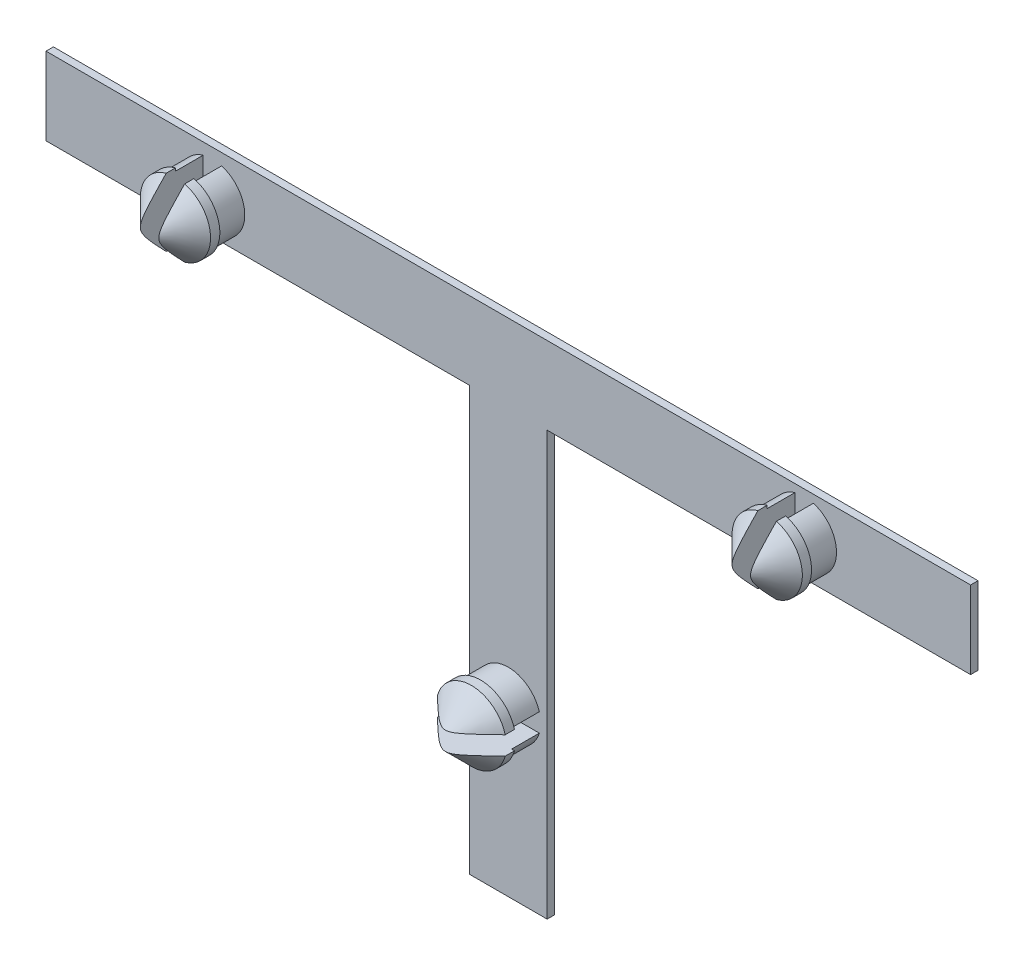
from build123d import *

# Parameters (mm, degrees)
SKICA2_W                 = 50
SKICA2_H                 = 4.2
P_IDAT_VYSUNUT_M2_DEPTH  = 0.4
SKICA3_R                 = 1.75
P_IDAT_VYSUNUT_M3_DEPTH  = 1.5
SKICA5_R                 = 1.9
P_IDAT_VYSUNUT_M5_DEPTH  = 2
ZKOSEN_2_SIZE            = 1.5
SKICA7_W                 = 1
SKICA7_H                 = 5
ODEBRAT_VYSUNUT_M1_DEPTH = 3.5
SKICA8_W                 = 4.2
SKICA8_H                 = 22.9
P_IDAT_VYSUNUT_M6_DEPTH  = 0.4
SKICA9_R                 = 1.75
P_IDAT_VYSUNUT_M7_DEPTH  = 1.5
SKICA10_R                = 1.9
P_IDAT_VYSUNUT_M8_DEPTH  = 2
ZKOSEN_3_SIZE            = 1.5
SKICA12_W                = 5
SKICA12_H                = 1
ODEBRAT_VYSUNUT_M2_DEPTH = 3.5


with BuildPart() as part:
    # Skica2 → Přidat vysunutím2 (new body)
    with BuildSketch(Plane.XY):
        Rectangle(SKICA2_W, SKICA2_H)
    extrude(amount=P_IDAT_VYSUNUT_M2_DEPTH)

    # Skica3 → Přidat vysunutím3 (add)
    with BuildSketch(Plane.XY.offset(0.4)):
        with Locations((-16, -0.2)):
            Circle(SKICA3_R)
        with Locations((16, 0)):
            Circle(SKICA3_R)
    extrude(amount=P_IDAT_VYSUNUT_M3_DEPTH)

    # Skica5 → Přidat vysunutím5 (add)
    with BuildSketch(Plane.XY.offset(1.9)):
        with Locations((-16, -0.2)):
            Circle(SKICA5_R)
        with Locations((16, 0)):
            Circle(SKICA5_R)
    extrude(amount=P_IDAT_VYSUNUT_M5_DEPTH)

    # Zkosení2
    zkosen_2_edges = [part.edges().sort_by_distance(p)[0] for p in [
        (-17.9, -0.2, 3.9),
        (14.1, 0, 3.9),
    ]]
    chamfer(zkosen_2_edges, length=ZKOSEN_2_SIZE)

    # Skica7 → Odebrat vysunutím1 (cut)
    with BuildSketch(Plane.XY.offset(3.9)):
        with Locations((-16, -0.2)):
            Rectangle(SKICA7_W, SKICA7_H)
        with Locations((16, 0)):
            Rectangle(SKICA7_W, SKICA7_H)
    extrude(amount=-ODEBRAT_VYSUNUT_M1_DEPTH, mode=Mode.SUBTRACT)

    # Skica8 → Přidat vysunutím6 (add)
    with BuildSketch(Plane(origin=(0, 0, 0), x_dir=(-1, 0, 0), z_dir=(0, 0, -1))):
        with Locations((0, -13.55)):
            Rectangle(SKICA8_W, SKICA8_H)
    extrude(amount=-P_IDAT_VYSUNUT_M6_DEPTH)

    # Skica9 → Přidat vysunutím7 (add)
    with BuildSketch(Plane.XY.offset(0.4)):
        with Locations((0, -16)):
            Circle(SKICA9_R)
    extrude(amount=P_IDAT_VYSUNUT_M7_DEPTH)

    # Skica10 → Přidat vysunutím8 (add)
    with BuildSketch(Plane.XY.offset(1.9)):
        with Locations((0, -16)):
            Circle(SKICA10_R)
    extrude(amount=P_IDAT_VYSUNUT_M8_DEPTH)

    # Zkosení3
    zkosen_3_edges = [part.edges().sort_by_distance(p)[0] for p in [
        (-1.9, -16, 3.9),
    ]]
    chamfer(zkosen_3_edges, length=ZKOSEN_3_SIZE)

    # Skica12 → Odebrat vysunutím2 (cut)
    with BuildSketch(Plane.XY.offset(3.9)):
        with Locations((0, -16)):
            Rectangle(SKICA12_W, SKICA12_H)
    extrude(amount=-ODEBRAT_VYSUNUT_M2_DEPTH, mode=Mode.SUBTRACT)


solid = part.part
